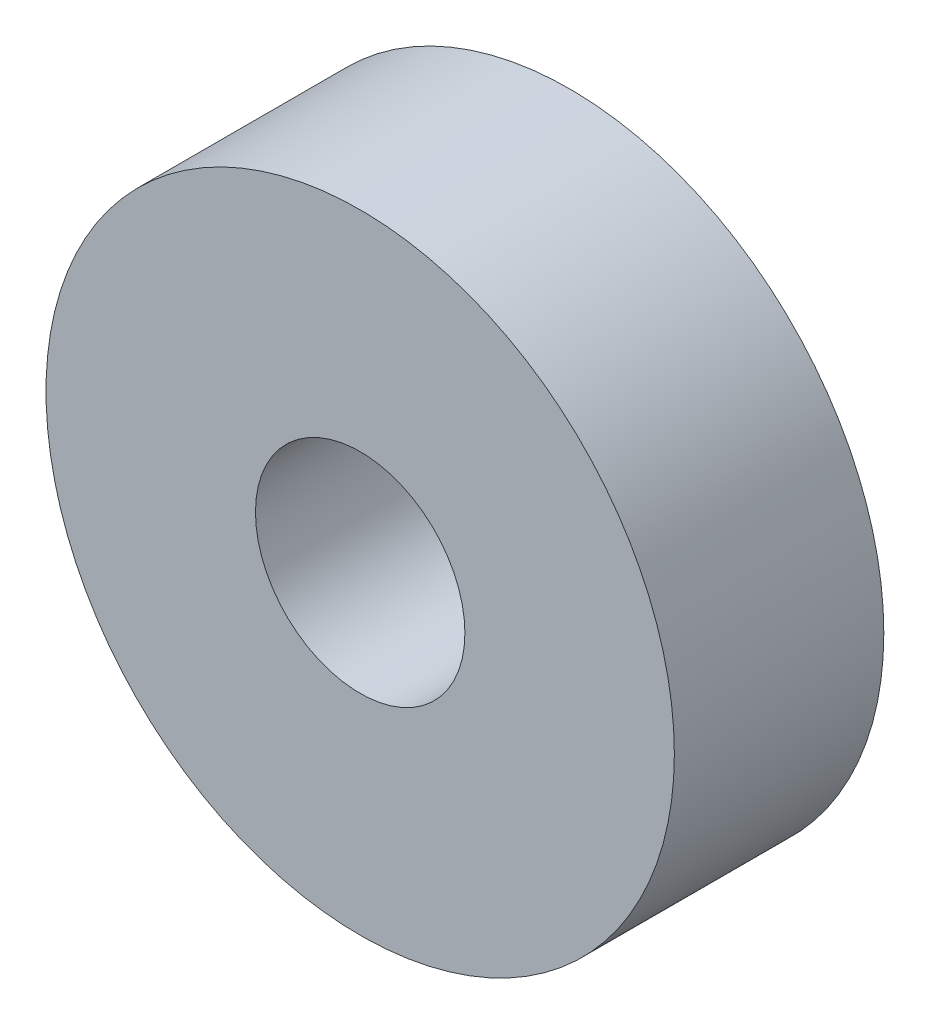
from build123d import *

# Parameters (mm, degrees)
SKETCH1_R           = 38.1
SKETCH1_R_2         = 12.7
BOSS_EXTRUDE1_DEPTH = 25.4


with BuildPart() as part:
    # Sketch1 → Boss-Extrude1 (new body)
    with BuildSketch(Plane.XY):
        Circle(SKETCH1_R)
        Circle(SKETCH1_R_2, mode=Mode.SUBTRACT)
    extrude(amount=BOSS_EXTRUDE1_DEPTH)

    # Cut-Sweep2: sweep along a path in Sketch2
    with BuildLine(Plane(origin=(0, 0, 0), x_dir=(-1, 0, 0), z_dir=(0, 0, -1))) as cut_sweep2_path:
        Line((-14.664696837, 25.4), (-29.329393675, 0))
        Line((-29.329393675, 0), (-14.664696837, -25.4))
        Line((-14.664696837, -25.4), (14.664696837, -25.4))
        Line((14.664696837, -25.4), (29.329393675, 0))
        Line((29.329393675, 0), (14.664696837, 25.4))
        Line((14.664696837, 25.4), (-14.664696837, 25.4))
    # Sketch3 → Cut-Sweep2 (sweep, cut)
    with BuildSketch(Plane(origin=(0, 0, 0), x_dir=(1, 0, 0), z_dir=(0, 1, 0))):
        with BuildLine():
            Line((-35.679393675, 0), (-22.979393675, 0))
            Line((-22.979393675, 0), (-22.979393675, -3.175))
            ThreePointArc((-22.979393675, -3.175), (-23.909329645, -5.42006403), (-26.154393675, -6.35))
            Line((-26.154393675, -6.35), (-32.504393675, -6.35))
            ThreePointArc((-32.504393675, -6.35), (-34.749457705, -5.42006403), (-35.679393675, -3.175))
            Line((-35.679393675, -3.175), (-35.679393675, 0))
        make_face()
    sweep(path=cut_sweep2_path.line, transition=Transition.RIGHT, mode=Mode.SUBTRACT)


solid = part.part
